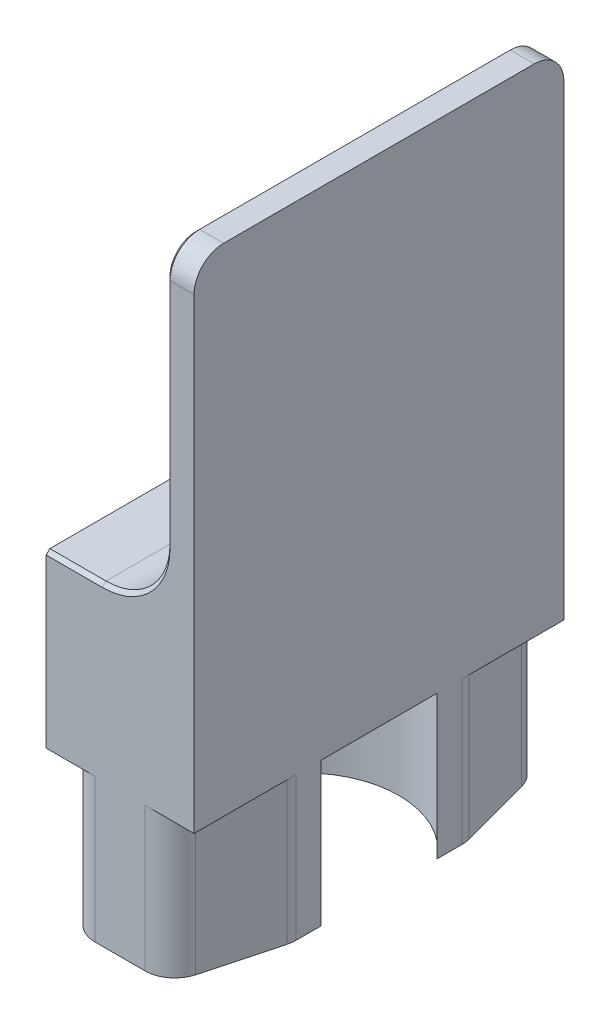
from build123d import *

# Parameters (mm, degrees)
BOSS_EXTRUDE1_DEPTH = 12.5
SKETCH3_R           = 6.3525
CUT_EXTRUDE1_DEPTH  = 9.7
FILLET1_R           = 2
CUT_EXTRUDE2_DEPTH  = 9.7
FILLET2_R           = 2
SKETCH7_W           = 21
SKETCH7_H           = 7.555
CUT_EXTRUDE3_DEPTH  = 8
FILLET3_R           = 2
CHAMFER1_SIZE       = 0.25


with BuildPart() as part:
    # Sketch2 → Boss-Extrude1 (new body, symmetric)
    with BuildSketch(Plane.XY):
        with BuildLine():
            Line((3.125, 22.23), (3.125, 39.905))
            Line((3.125, 39.905), (5, 39.905))
            Line((5, 39.905), (5, -3.35))
            Line((5, -3.35), (-5, -3.35))
            Line((-5, -3.35), (-5, 17.905))
            Line((-5, 17.905), (-1.2, 17.905))
            ThreePointArc((-1.2, 17.905), (1.858236829, 19.171763171), (3.125, 22.23))
        make_face()
    extrude(amount=BOSS_EXTRUDE1_DEPTH, both=True)

    # Sketch3 → Cut-Extrude1 (cut)
    with BuildSketch(Plane.XZ.offset(3.35)):
        Circle(SKETCH3_R)
    extrude(amount=-CUT_EXTRUDE1_DEPTH, mode=Mode.SUBTRACT)

    # Fillet1
    fillet1_edges = [part.edges().sort_by_distance(p)[0] for p in [
        (4.0625, 39.905, 12.5),
        (4.0625, 39.905, -12.5),
    ]]
    fillet(fillet1_edges, radius=FILLET1_R)

    # Sketch6 → Cut-Extrude2 (cut)
    with BuildSketch(Plane.XZ.offset(3.35)):
        Polygon((0, 24.544175246), (-5.421515272, 4.310804798), (-5.421515272, 3.310804798), (-5.421515272, 0), (-10.421515272, 0), (-10.421515272, 29.544175246), (10.421515272, 29.544175246), (10.421515272, 0), (5.421515272, 0), (5.421515272, 3.310804798), (5.421515272, 4.310804798), align=None)
    cut_extrude2 = extrude(amount=-CUT_EXTRUDE2_DEPTH, mode=Mode.SUBTRACT)

    # Mirror1: Cut-Extrude2 across plane
    add(cut_extrude2.mirror(Plane.XY), mode=Mode.SUBTRACT)

    # Fillet2
    fillet2_edges = [part.edges().sort_by_distance(p)[0] for p in [
        (-3.227227031, 1.5, 12.5),
        (3.227227031, 1.5, 12.5),
        (5, 1.5, 5.883921208),
        (-5, 1.5, 5.883921208),
        (-3.227227031, 1.5, -12.5),
        (3.227227031, 1.5, -12.5),
        (-5, 1.5, -5.883921208),
        (5, 1.5, -5.883921208),
    ]]
    fillet(fillet2_edges, radius=FILLET2_R)

    # Sketch7 → Cut-Extrude3 (cut)
    with BuildSketch(Plane.ZY.offset(5)):
        with Locations((0, 12.1275)):
            Rectangle(SKETCH7_W, SKETCH7_H)
    extrude(amount=-CUT_EXTRUDE3_DEPTH, mode=Mode.SUBTRACT)

    # Fillet3
    fillet3_edges = [part.edges().sort_by_distance(p)[0] for p in [
        (-1, 8.35, -10.5),
        (-1, 15.905, -10.5),
        (-1, 15.905, 10.5),
        (-1, 8.35, 10.5),
    ]]
    fillet(fillet3_edges, radius=FILLET3_R)

    # Chamfer1
    chamfer1_edges = [part.edges().sort_by_distance(p)[0] for p in [
        (-5, 12.1275, 10.5),
        (-5, 8.35, 0),
        (-5, 12.1275, -10.5),
        (-5, 15.905, 0),
        (-5, 8.935786438, 9.914213562),
        (-5, 8.935786438, -9.914213562),
        (-5, 15.319213562, 9.914213562),
        (-5, 15.319213562, -9.914213562),
        (3.125, 39.905, 0),
        (3.125, 30.0675, -12.5),
        (3.125, 30.0675, 12.5),
        (3.125, 39.319213562, 11.914213562),
        (1.858236829, 19.171763171, 12.5),
        (3.125, 39.319213562, -11.914213562),
        (-3.1, 17.905, 12.5),
        (-3.1, 17.905, -12.5),
        (1.858236829, 19.171763171, -12.5),
    ]]
    chamfer(chamfer1_edges, length=CHAMFER1_SIZE)


solid = part.part
